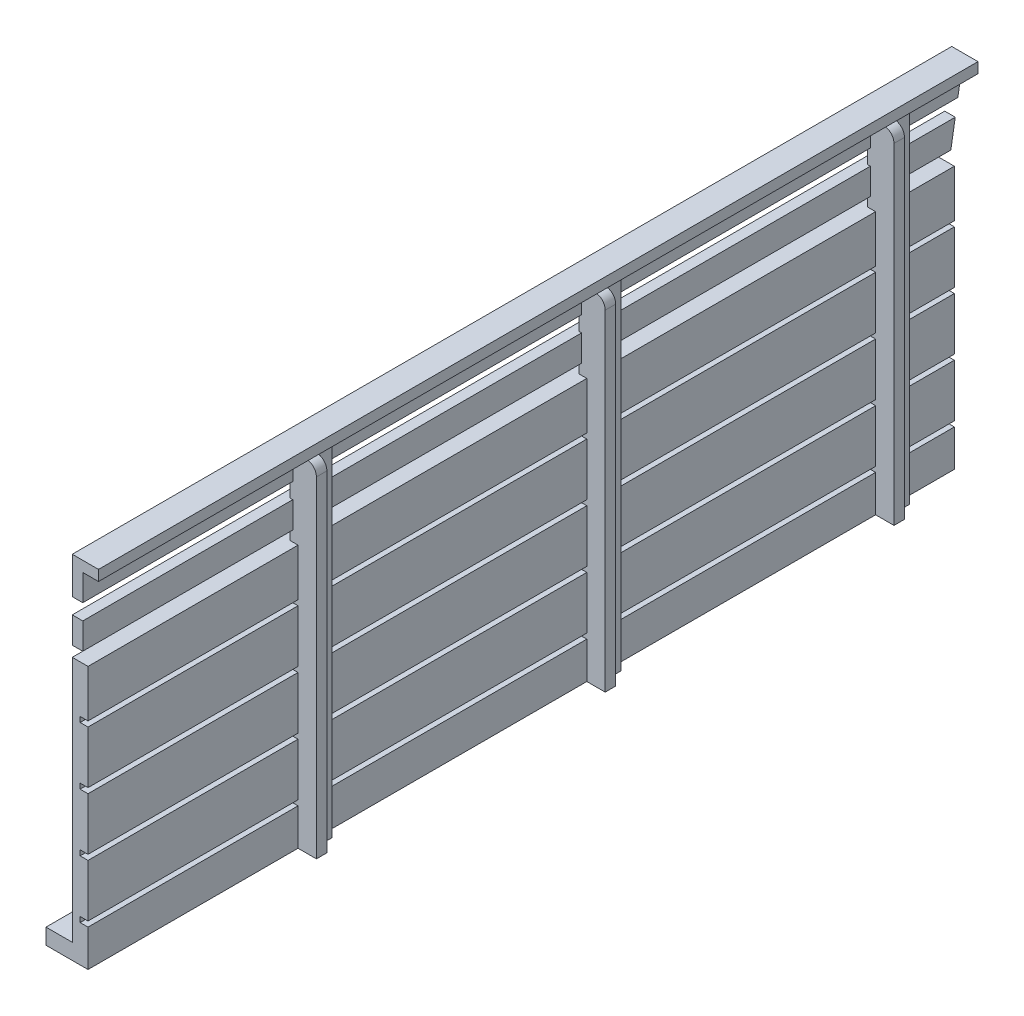
from build123d import *

# Parameters (mm, degrees)
SKETCH1_W           = 165
SKETCH1_H           = 50
BOSS_EXTRUDE1_DEPTH = 3
SKETCH3_W           = 165
SKETCH3_H           = 1
CUT_EXTRUDE1_DEPTH  = 1.5
SKETCH4_W           = 5
SKETCH4_H           = 65
BOSS_EXTRUDE2_DEPTH = 1.5
SKETCH5_W           = 2
SKETCH5_H           = 65
BOSS_EXTRUDE3_DEPTH = 2
FILLET1_R           = 2
SKETCH8_W           = 167.5
SKETCH8_H           = 5
BOSS_EXTRUDE4_DEPTH = 2
SKETCH6_W           = 5
SKETCH6_H           = 167.5
BOSS_EXTRUDE5_DEPTH = 2
CUT_EXTRUDE2_DEPTH  = 3
SKETCH10_W          = 165
SKETCH10_H          = 3
BOSS_EXTRUDE6_DEPTH = 5
SKETCH11_W          = 5
SKETCH11_H          = 3
CUT_EXTRUDE3_DEPTH  = 3


with BuildPart() as part:
    # Sketch1 → Boss-Extrude1 (new body)
    with BuildSketch(Plane(origin=(0, 0, 0), x_dir=(0, 0, -1), z_dir=(1, 0, 0))):
        Rectangle(SKETCH1_W, SKETCH1_H)
    extrude(amount=BOSS_EXTRUDE1_DEPTH)

    # Sketch3 → Cut-Extrude1 (cut)
    with BuildSketch(Plane(origin=(3, 0, 0), x_dir=(0, 0, -1), z_dir=(1, 0, 0))):
        with Locations((0, -17.5)):
            Rectangle(SKETCH3_W, SKETCH3_H)
        with Locations((0, -6.5)):
            Rectangle(SKETCH3_W, SKETCH3_H)
        with Locations((0, 4.5)):
            Rectangle(SKETCH3_W, SKETCH3_H)
        with Locations((0, 15.5)):
            Rectangle(SKETCH3_W, SKETCH3_H)
    extrude(amount=-CUT_EXTRUDE1_DEPTH, mode=Mode.SUBTRACT)

    # Sketch4 → Boss-Extrude2 (add, symmetric)
    with BuildSketch(Plane(origin=(3, 0, 0), x_dir=(0, 0, -1), z_dir=(1, 0, 0))):
        with Locations((-40, 7.5)):
            Rectangle(SKETCH4_W, SKETCH4_H)
        with Locations((15, 7.5)):
            Rectangle(SKETCH4_W, SKETCH4_H)
        with Locations((70, 7.5)):
            Rectangle(SKETCH4_W, SKETCH4_H)
    extrude(amount=BOSS_EXTRUDE2_DEPTH, both=True)

    # Sketch5 → Boss-Extrude3 (add)
    with BuildSketch(Plane(origin=(4.5, 0, 0), x_dir=(0, 0, -1), z_dir=(1, 0, 0))):
        with Locations((-41.5, 7.5)):
            Rectangle(SKETCH5_W, SKETCH5_H)
        with Locations((13.5, 7.5)):
            Rectangle(SKETCH5_W, SKETCH5_H)
        with Locations((68.5, 7.5)):
            Rectangle(SKETCH5_W, SKETCH5_H)
    extrude(amount=BOSS_EXTRUDE3_DEPTH)

    # Fillet1
    fillet1_edges = [part.edges().sort_by_distance(p)[0] for p in [
        (6.5, 40, -68.5),
        (6.5, 40, -13.5),
        (6.5, 40, 41.5),
    ]]
    fillet(fillet1_edges, radius=FILLET1_R)

    # Sketch8 → Boss-Extrude4 (add)
    with BuildSketch(Plane.ZY):
        with Locations((-1.25, 37.5)):
            Rectangle(SKETCH8_W, SKETCH8_H)
        with Locations((-1.25, 29.5)):
            Rectangle(SKETCH8_W, SKETCH8_H)
    extrude(amount=-BOSS_EXTRUDE4_DEPTH)

    # Sketch6 → Boss-Extrude5 (add)
    with BuildSketch(Plane(origin=(0, 40, 0), x_dir=(1, 0, 0), z_dir=(0, 1, 0))):
        with Locations((2.5, 1.25)):
            Rectangle(SKETCH6_W, SKETCH6_H)
    extrude(amount=BOSS_EXTRUDE5_DEPTH)

    # Sketch9 → Cut-Extrude2 (cut)
    with BuildSketch(Plane(origin=(3, 0, 0), x_dir=(0, 0, -1), z_dir=(1, 0, 0))):
        Polygon((82.5, 25), (85, 40), (86.823403956, 40), (86.823403956, 25), align=None)
    extrude(amount=-CUT_EXTRUDE2_DEPTH, mode=Mode.SUBTRACT)

    # Sketch10 → Boss-Extrude6 (add)
    with BuildSketch(Plane.ZY):
        with Locations((0, -23.5)):
            Rectangle(SKETCH10_W, SKETCH10_H)
    extrude(amount=BOSS_EXTRUDE6_DEPTH)

    # Sketch11 → Cut-Extrude3 (cut)
    with BuildSketch(Plane(origin=(0, -22, 0), x_dir=(1, 0, 0), z_dir=(0, 1, 0))):
        with Locations((-2.5, 81)):
            Rectangle(SKETCH11_W, SKETCH11_H)
    extrude(amount=-CUT_EXTRUDE3_DEPTH, mode=Mode.SUBTRACT)


solid = part.part
